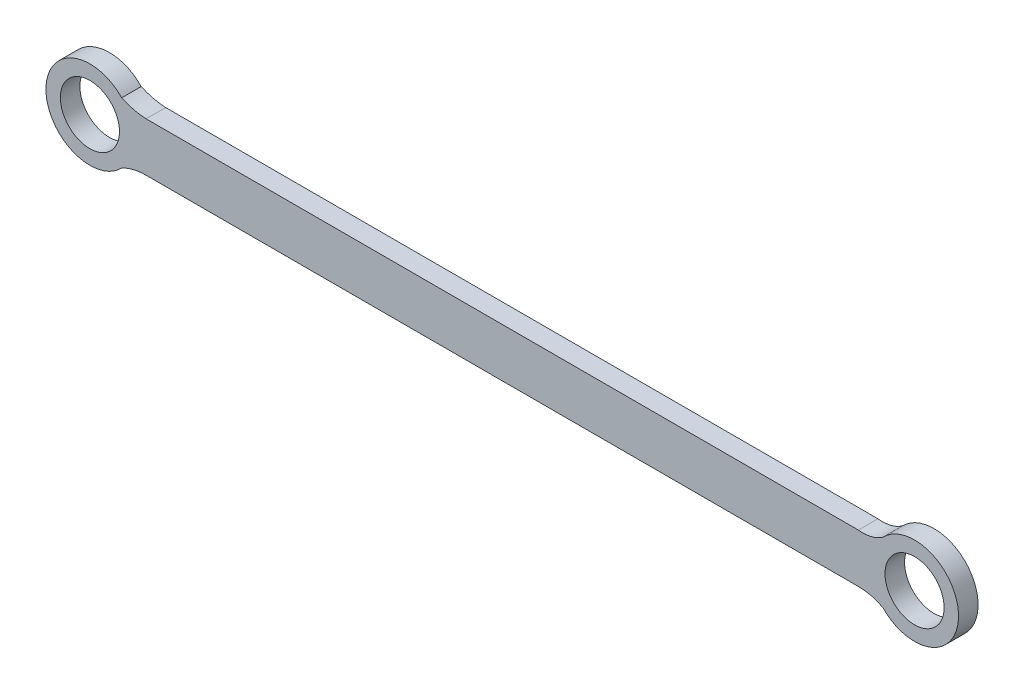
from build123d import *

# Parameters (mm, degrees)
SKETCH_1_R      = 6.05
EXTRUDE_1_DEPTH = 4


with BuildPart() as part:
    # 草图1 → 凸台-拉伸1 (new body)
    with BuildSketch(Plane.XY):
        with BuildLine():
            Line((82, 4.500949209), (-63.75, 4.500949209))
            ThreePointArc((-63.75, 4.500949209), (-66.309809086, 4.867908106), (-68.75, 5.723916101))
            ThreePointArc((-68.75, 5.723916101), (-84.25189842, -0.499050791), (-68.75, -6.722017682))
            ThreePointArc((-68.75, -6.722017682), (-66.326896981, -5.796147226), (-63.75, -5.499050791))
            Line((-63.75, -5.499050791), (82, -5.499050791))
            ThreePointArc((82, -5.499050791), (84.57416787, -5.810267104), (87, -6.725982287))
            ThreePointArc((87, -6.725982287), (102.49810158, -0.499050791), (87, 5.727880705))
            ThreePointArc((87, 5.727880705), (84.615493422, 4.64375534), (82, 4.500949209))
        make_face()
        with Locations((-75.25189842, -0.499050791)):
            Circle(SKETCH_1_R, mode=Mode.SUBTRACT)
        with Locations((93.49810158, -0.499050791)):
            Circle(SKETCH_1_R, mode=Mode.SUBTRACT)
    extrude(amount=EXTRUDE_1_DEPTH)


solid = part.part
